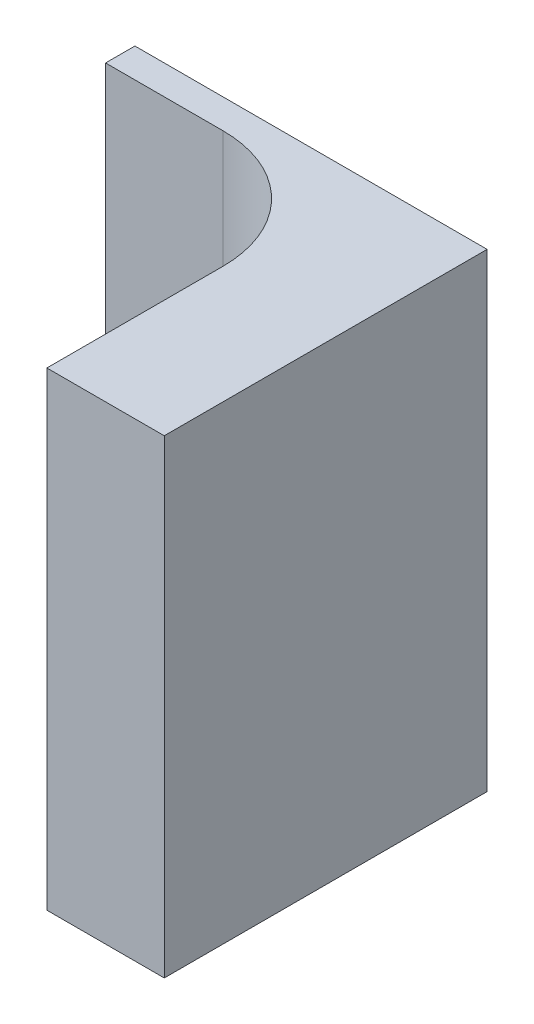
from build123d import *

# Parameters (mm, degrees)
BOSS_EXTRUDE1_DEPTH = 3.175
SKETCH2_W           = 12.7
SKETCH2_H           = 50.8
BOSS_EXTRUDE2_DEPTH = 31.75
FILLET1_R           = 12.7


with BuildPart() as part:
    # Sketch1 → Boss-Extrude1 (new body)
    with BuildSketch(Plane.XY.offset(15.875)):
        Polygon((-38.1, 25.4), (-38.1, -25.4), (-25.4, -25.4), (0, -25.4), (0, 25.4), align=None)
    extrude(amount=BOSS_EXTRUDE1_DEPTH)

    # Sketch2 → Boss-Extrude2 (add)
    with BuildSketch(Plane.XY.offset(50.8)):
        with Locations((-6.35, 0)):
            Rectangle(SKETCH2_W, SKETCH2_H)
    extrude(amount=-BOSS_EXTRUDE2_DEPTH)

    # Fillet1
    fillet1_edges = [part.edges().sort_by_distance(p)[0] for p in [
        (-12.7, 0, 19.05),
    ]]
    fillet(fillet1_edges, radius=FILLET1_R)


solid = part.part
